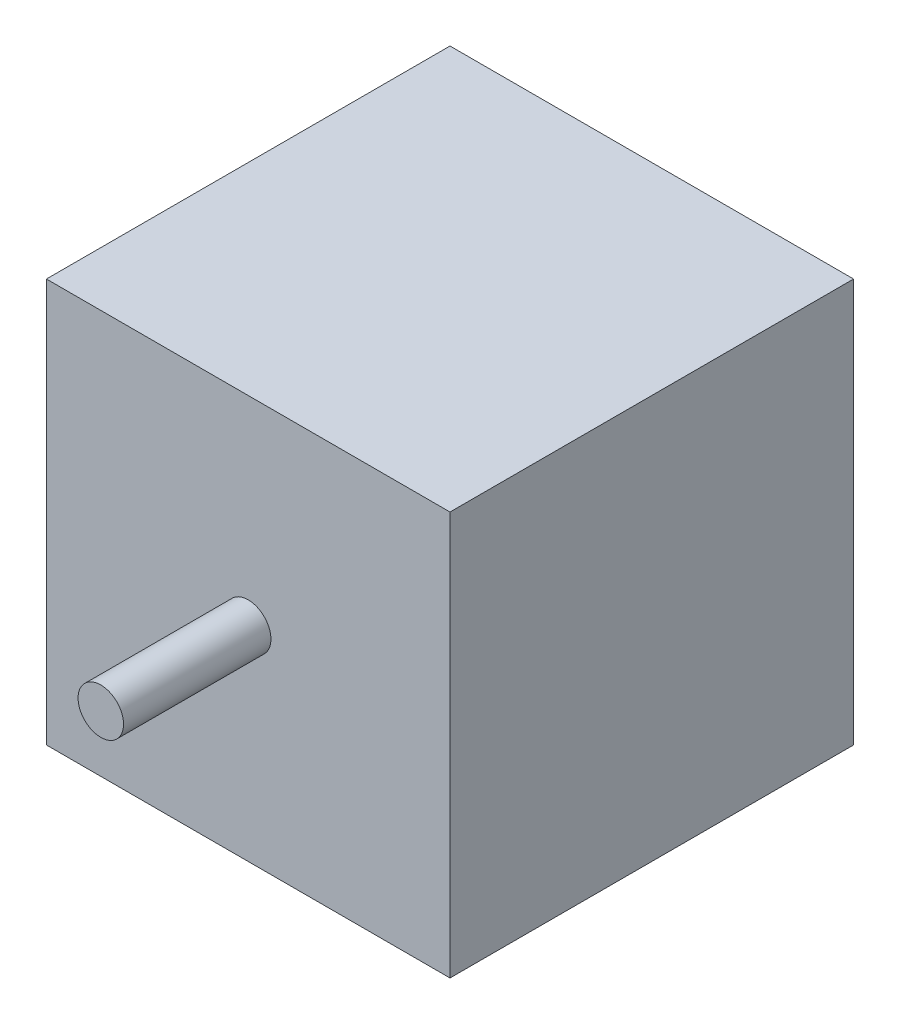
from build123d import *

# Parameters (mm, degrees)
SKETCH1_W           = 56.399938
SKETCH1_H           = 56.399938
BOSS_EXTRUDE1_DEPTH = 56.399938
SKETCH2_R           = 3.175
BOSS_EXTRUDE2_DEPTH = 20.59999944


with BuildPart() as part:
    # Sketch1 → Boss-Extrude1 (new body)
    with BuildSketch(Plane(origin=(0, 0, 0), x_dir=(1, 0, 0), z_dir=(0, 1, 0))):
        Rectangle(SKETCH1_W, SKETCH1_H)
    extrude(amount=BOSS_EXTRUDE1_DEPTH)

    # Sketch2 → Boss-Extrude2 (add)
    with BuildSketch(Plane.XY.offset(28.199969)):
        with Locations((0, 28.495326657)):
            Circle(SKETCH2_R)
    extrude(amount=BOSS_EXTRUDE2_DEPTH)


solid = part.part
